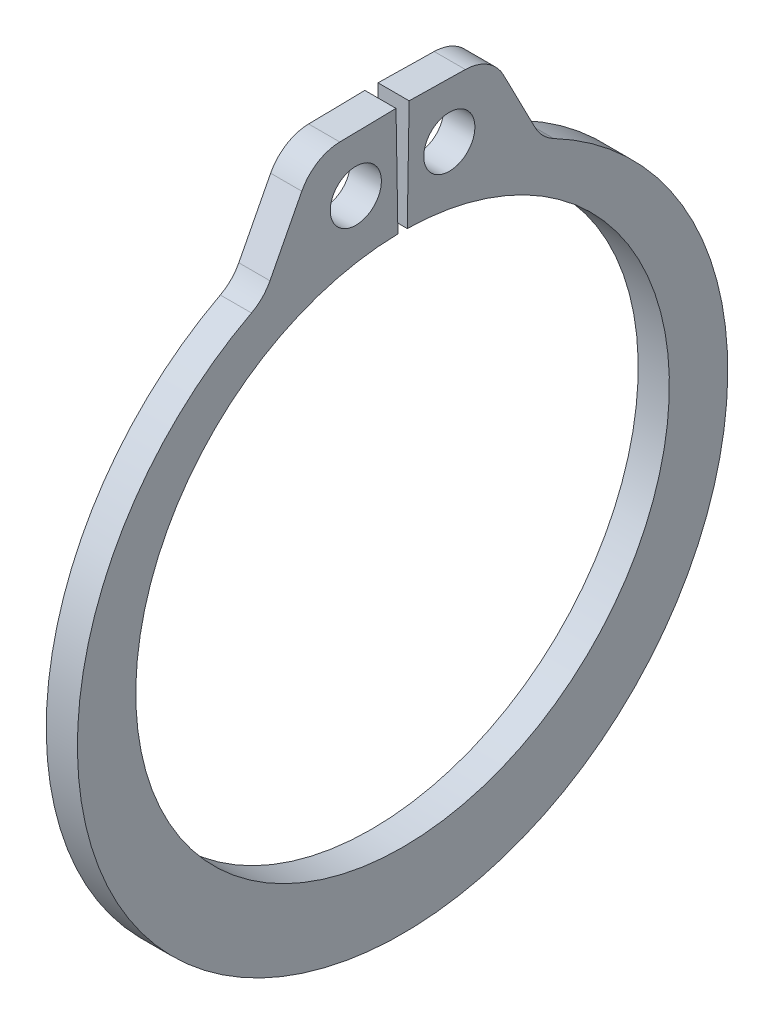
from build123d import *

# Parameters (mm, degrees)
SKETCH1_R      = 0.5207
EXTRUDE1_DEPTH = 0.3175
FILLET1_R      = 0.889


with BuildPart() as part:
    # Sketch1 → Extrude1 (new body, symmetric)
    with BuildSketch(Plane(origin=(0, 0, 0), x_dir=(0, 0, -1), z_dir=(1, 0, 0))):
        with BuildLine():
            Line((-0.0948643, 5.434772132), (-0.133873919, 7.6696317))
            Line((-0.133873919, 7.6696317), (-1.810018595, 7.640374486))
            Line((-1.810018595, 7.640374486), (-2.834582122, 5.653822543))
            ThreePointArc((-2.834582122, 5.653822543), (0, -6.9596), (2.834582122, 5.653822543))
            Line((2.834582122, 5.653822543), (1.810018595, 7.640374486))
            Line((1.810018595, 7.640374486), (0.133873919, 7.6696317))
            Line((0.133873919, 7.6696317), (0.0948643, 5.434772132))
            ThreePointArc((0.0948643, 5.434772132), (0, -5.4356), (-0.0948643, 5.434772132))
        make_face()
        with Locations((-0.952441448, 6.537573309)):
            Circle(SKETCH1_R, mode=Mode.SUBTRACT)
        with Locations((0.952441448, 6.537573309)):
            Circle(SKETCH1_R, mode=Mode.SUBTRACT)
    extrude(amount=EXTRUDE1_DEPTH, both=True)

    # Fillet1
    fillet1_edges = [part.edges().sort_by_distance(p)[0] for p in [
        (0, 7.640374486, -1.810018595),
        (0, 5.653822543, -2.834582122),
        (0, 5.653822543, 2.834582122),
        (0, 7.640374486, 1.810018595),
    ]]
    fillet(fillet1_edges, radius=FILLET1_R)


solid = part.part
